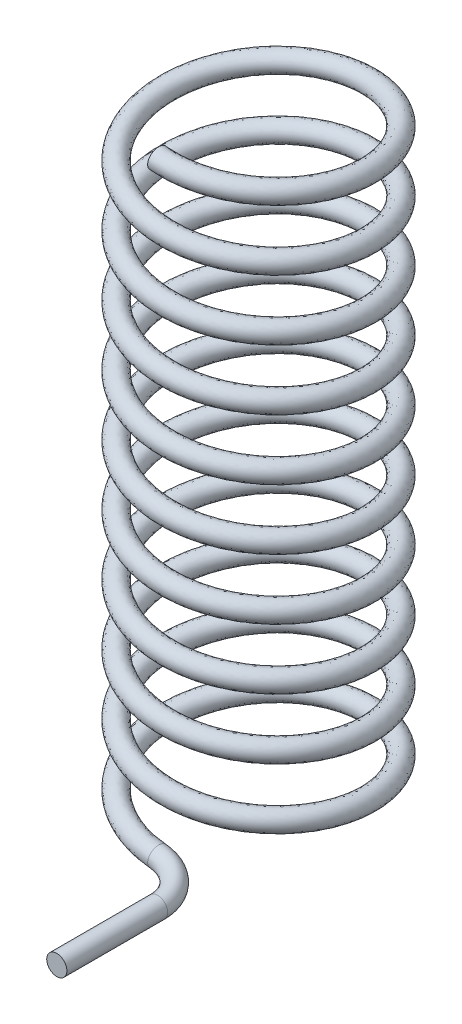
from build123d import *

# Parameters (mm, degrees)
SKIZZE3_R = 0.5


with BuildPart() as part:
    # Austragung1: sweep along a curve in space
    with BuildLine() as austragung1_path:
        Line((1.990942989, -0.190121051, 7), (1.990942989, -0.190121051, 12))
        ThreePointArc((0, 0, 5), (1.407809289, -0.134435884, 5.585786438), (1.990942989, -0.190121051, 7))
        add(Edge.make_bspline(
            [(0, 0, 5), (-0.650339125, 0.062102812, 5), (-1.965120671, 0.187684336, 4.739659358), (-3.627071937, 0.374950607, 3.627578223), (-4.739795017, 0.562513235, 1.963231187), (-5.130133971, 0.749996454, 0), (-4.739669098, 0.93750095, -1.963231187), (-3.627575613, 1.124999745, -3.627578223), (-1.963231886, 1.312500068, -4.739659358), (1.87e-07, 1.499999982, -5.130170321), (1.963231137, 1.687500005, -4.739659358), (3.627578236, 1.874999999, -3.627578223), (4.739659354, 2.0625, -1.963231187), (5.130170322, 2.25, 0), (4.739659358, 2.4375, 1.963231187), (3.627578223, 2.625, 3.627578223), (1.963231187, 2.8125, 4.739659358), (0, 3, 5.130170321), (-1.963231187, 3.1875, 4.739659358), (-3.627578223, 3.375, 3.627578223), (-4.739659358, 3.5625, 1.963231187), (-5.130170321, 3.75, 0), (-4.739659358, 3.9375, -1.963231187), (-3.627578223, 4.125, -3.627578223), (-1.963231187, 4.3125, -4.739659358), (0, 4.5, -5.130170321), (1.963231187, 4.6875, -4.739659358), (3.627578223, 4.875, -3.627578223), (4.739659358, 5.0625, -1.963231187), (5.130170321, 5.25, 0), (4.739659358, 5.4375, 1.963231187), (3.627578223, 5.625, 3.627578223), (1.963231187, 5.8125, 4.739659358), (0, 6, 5.130170321), (-1.963231187, 6.1875, 4.739659358), (-3.627578223, 6.375, 3.627578223), (-4.739659358, 6.5625, 1.963231187), (-5.130170321, 6.75, 0), (-4.739659358, 6.9375, -1.963231187), (-3.627578223, 7.125, -3.627578223), (-1.963231187, 7.3125, -4.739659358), (0, 7.5, -5.130170321), (1.963231187, 7.6875, -4.739659358), (3.627578223, 7.875, -3.627578223), (4.739659358, 8.0625, -1.963231187), (5.130170321, 8.25, 0), (4.739659358, 8.4375, 1.963231187), (3.627578223, 8.625, 3.627578223), (1.963231187, 8.8125, 4.739659358), (0, 9, 5.130170321), (-1.963231187, 9.1875, 4.739659358), (-3.627578223, 9.375, 3.627578223), (-4.739659358, 9.5625, 1.963231187), (-5.130170321, 9.75, 0), (-4.739659358, 9.9375, -1.963231187), (-3.627578223, 10.125, -3.627578223), (-1.963231187, 10.3125, -4.739659358), (0, 10.5, -5.130170321), (1.963231187, 10.6875, -4.739659358), (3.627578223, 10.875, -3.627578223), (4.739659358, 11.0625, -1.963231187), (5.130170321, 11.25, 0), (4.739659358, 11.4375, 1.963231187), (3.627578223, 11.625, 3.627578223), (1.963231187, 11.8125, 4.739659358), (0, 12, 5.130170321), (-1.963231187, 12.1875, 4.739659358), (-3.627578223, 12.375, 3.627578223), (-4.739659358, 12.5625, 1.963231187), (-5.130170321, 12.75, 0), (-4.739659358, 12.9375, -1.963231187), (-3.627578223, 13.125, -3.627578223), (-1.963231187, 13.3125, -4.739659358), (0, 13.5, -5.130170321), (1.963231187, 13.6875, -4.739659358), (3.627578223, 13.875, -3.627578223), (4.739659358, 14.0625, -1.963231187), (5.130170321, 14.25, 0), (4.739659358, 14.4375, 1.963231187), (3.627578223, 14.625, 3.627578223), (1.963231187, 14.8125, 4.739659358), (0, 15, 5.130170321), (-1.963231187, 15.1875, 4.739659358), (-3.627578223, 15.375, 3.627578223), (-4.739659358, 15.5625, 1.963231187), (-5.130170321, 15.75, 0), (-4.739659358, 15.9375, -1.963231187), (-3.627578223, 16.125, -3.627578223), (-1.963231187, 16.3125, -4.739659358), (0, 16.5, -5.130170321), (1.963231187, 16.6875, -4.739659358), (3.627578223, 16.875, -3.627578223), (4.739659358, 17.0625, -1.963231187), (5.130170321, 17.25, 0), (4.739659358, 17.4375, 1.963231187), (3.627578223, 17.625, 3.627578223), (1.963231187, 17.8125, 4.739659358), (0, 18, 5.130170321), (-1.963231187, 18.1875, 4.739659358), (-3.627578223, 18.375, 3.627578223), (-4.739659358, 18.5625, 1.963231187), (-5.130170321, 18.75, 0), (-4.739659358, 18.9375, -1.963231187), (-3.627578223, 19.125, -3.627578223), (-1.963231187, 19.3125, -4.739659358), (0, 19.5, -5.130170321), (1.963231187, 19.6875, -4.739659358), (3.627578223, 19.875, -3.627578223), (4.739659358, 20.0625, -1.963231187), (5.130170321, 20.25, 0), (4.739659358, 20.4375, 1.963231187), (3.627578223, 20.625, 3.627578223), (1.963231187, 20.8125, 4.739659358), (0, 21, 5.130170321), (-1.963231187, 21.1875, 4.739659358), (-3.627578223, 21.375, 3.627578223), (-4.739659358, 21.5625, 1.963231187), (-5.130170321, 21.75, 0), (-4.739659358, 21.9375, -1.963231187), (-3.627578223, 22.125, -3.627578223), (-1.963231187, 22.3125, -4.739659358), (0, 22.5, -5.130170321), (1.963231187, 22.6875, -4.739659358), (3.627578223, 22.875, -3.627578223), (4.739659358, 23.0625, -1.963231187), (5.130170321, 23.25, 0), (4.739659358, 23.4375, 1.963231187), (3.627578223, 23.625, 3.627578223), (1.963231187, 23.8125, 4.739659358), (0, 24, 5.130170321), (-1.963231187, 24.1875, 4.739659358), (-3.627578223, 24.375, 3.627578223), (-4.739659358, 24.5625, 1.963231187), (-5.130170321, 24.75, 0), (-4.739659358, 24.9375, -1.963231187), (-3.627578223, 25.125, -3.627578223), (-1.963231187, 25.3125, -4.739659358), (0, 25.5, -5.130170321), (1.963231187, 25.6875, -4.739659358), (3.627578223, 25.875, -3.627578223), (4.739659358, 26.0625, -1.963231187), (5.130170321, 26.25, 0), (4.739659358, 26.4375, 1.963231187), (3.627578223, 26.625, 3.627578223), (1.963231187, 26.8125, 4.739659358), (0, 27, 5.130170321), (-1.963231187, 27.1875, 4.739659358), (-3.627578223, 27.375, 3.627578223), (-4.739659358, 27.5625, 1.963231187), (-5.130170322, 27.75, 0), (-4.739659354, 27.9375, -1.963231187), (-3.627578236, 28.125000001, -3.627578223), (-1.963231137, 28.312499995, -4.739659358), (-1.87e-07, 28.500000018, -5.130170321), (1.963231886, 28.687499932, -4.739659358), (3.627575613, 28.875000255, -3.627578223), (4.739669098, 29.06249905, -1.963231187), (5.130133971, 29.250003546, 0), (4.739795017, 29.437486765, 1.963231187), (3.627071937, 29.625049393, 3.627578223), (1.965010052, 29.812328129, 4.739733378), (0.650076588, 29.937922264, 5.00005198), (-0.000389576, 30.000037202, 4.999999984)],
            knots=[0, 0, 0, 0, 0.00625, 0.0125, 0.01875, 0.025, 0.03125, 0.0375, 0.04375, 0.05, 0.05625, 0.0625, 0.06875, 0.075, 0.08125, 0.0875, 0.09375, 0.1, 0.10625, 0.1125, 0.11875, 0.125, 0.13125, 0.1375, 0.14375, 0.15, 0.15625, 0.1625, 0.16875, 0.175, 0.18125, 0.1875, 0.19375, 0.2, 0.20625, 0.2125, 0.21875, 0.225, 0.23125, 0.2375, 0.24375, 0.25, 0.25625, 0.2625, 0.26875, 0.275, 0.28125, 0.2875, 0.29375, 0.3, 0.30625, 0.3125, 0.31875, 0.325, 0.33125, 0.3375, 0.34375, 0.35, 0.35625, 0.3625, 0.36875, 0.375, 0.38125, 0.3875, 0.39375, 0.4, 0.40625, 0.4125, 0.41875, 0.425, 0.43125, 0.4375, 0.44375, 0.45, 0.45625, 0.4625, 0.46875, 0.475, 0.48125, 0.4875, 0.49375, 0.5, 0.50625, 0.5125, 0.51875, 0.525, 0.53125, 0.5375, 0.54375, 0.55, 0.55625, 0.5625, 0.56875, 0.575, 0.58125, 0.5875, 0.59375, 0.6, 0.60625, 0.6125, 0.61875, 0.625, 0.63125, 0.6375, 0.64375, 0.65, 0.65625, 0.6625, 0.66875, 0.675, 0.68125, 0.6875, 0.69375, 0.7, 0.70625, 0.7125, 0.71875, 0.725, 0.73125, 0.7375, 0.74375, 0.75, 0.75625, 0.7625, 0.76875, 0.775, 0.78125, 0.7875, 0.79375, 0.8, 0.80625, 0.8125, 0.81875, 0.825, 0.83125, 0.8375, 0.84375, 0.85, 0.85625, 0.8625, 0.86875, 0.875, 0.88125, 0.8875, 0.89375, 0.9, 0.90625, 0.9125, 0.91875, 0.925, 0.93125, 0.9375, 0.94375, 0.95, 0.95625, 0.9625, 0.96875, 0.975, 0.98125, 0.9875, 0.99375, 1.000001248, 1.000001248, 1.000001248, 1.000001248], degree=3))
    # Skizze3 → Austragung1 (sweep)
    with BuildSketch(Plane(origin=(1.990942989, -0.190121051, 12), x_dir=(1, 0, 0), z_dir=(0, 0, 1))):
        Circle(SKIZZE3_R)
    sweep(path=austragung1_path.line)


solid = part.part
